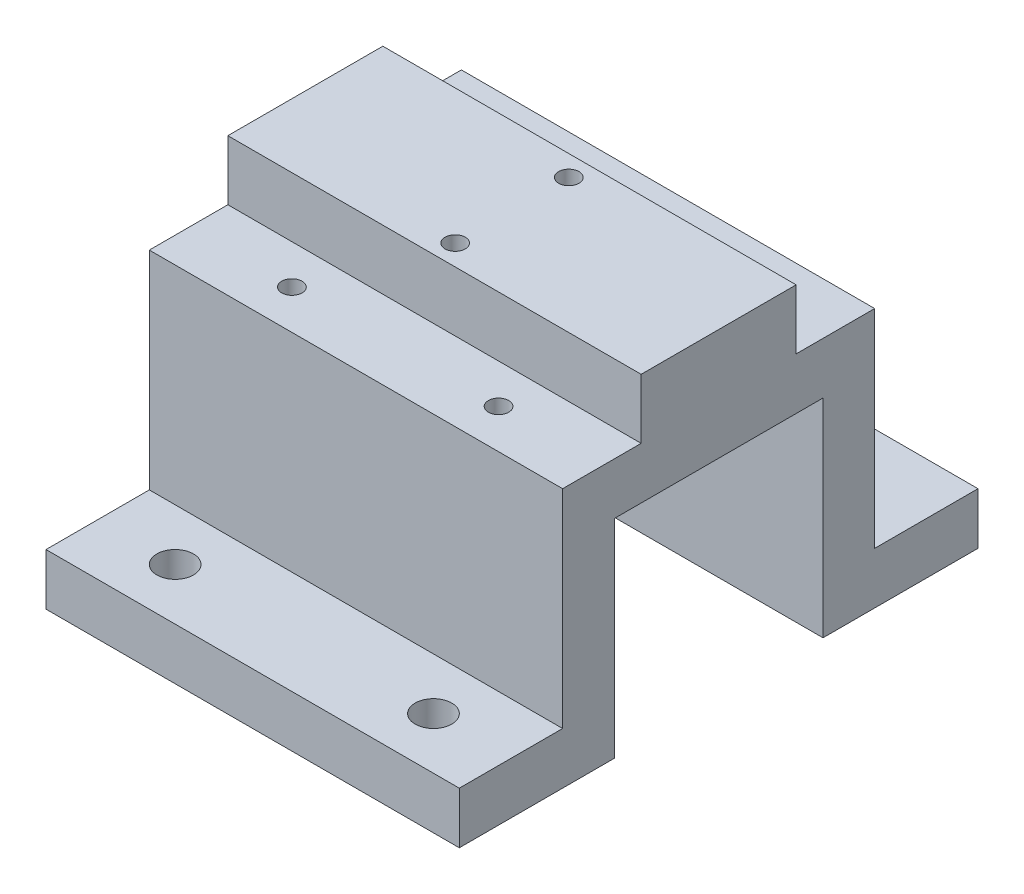
from build123d import *

# Parameters (mm, degrees)
SKETCH1_W                 = 12.7
SKETCH1_H                 = 6.35
BOSS_EXTRUDE1_DEPTH       = 50.8
SKETCH2_W                 = 50.8
SKETCH2_H                 = 19.05
BOSS_EXTRUDE2_DEPTH       = 7.35076
M3X0_5_TAPPED_HOLE1_D     = 2.5
M3X0_5_TAPPED_HOLE1_DEPTH = 6.35
M3X0_5_TAPPED_HOLE1_TIP   = 0.751075774
M3X0_5_TAPPED_HOLE2_D     = 2.5
M4_CLEARANCE_HOLE1_D      = 4.5


with BuildPart() as part:
    # Sketch1 → Boss-Extrude1 (new body)
    with BuildSketch(Plane(origin=(0, 0, 0), x_dir=(0, 0, -1), z_dir=(1, 0, 0))):
        Polygon((19.177, 6.35), (19.177, 31.877), (0, 31.877), (0, 25.527), (12.827, 25.527), (12.827, 0), (19.177, 0), align=None)
        with Locations((25.527, 3.175)):
            Rectangle(SKETCH1_W, SKETCH1_H)
        Polygon((0, 25.527), (0, 31.877), (-19.177, 31.877), (-19.177, 6.35), (-19.177, 0), (-12.827, 0), (-12.827, 25.527), align=None)
        with Locations((-25.527, 3.175)):
            Rectangle(SKETCH1_W, SKETCH1_H)
    extrude(amount=BOSS_EXTRUDE1_DEPTH)

    # Sketch2 → Boss-Extrude2 (add)
    with BuildSketch(Plane(origin=(0, 31.877, 0), x_dir=(1, 0, 0), z_dir=(0, 1, 0))):
        with Locations((25.4, 0)):
            Rectangle(SKETCH2_W, SKETCH2_H)
    extrude(amount=BOSS_EXTRUDE2_DEPTH)

    # M3x0.5 Tapped Hole1
    with Locations(Plane(origin=(0, 39.22776, 0), x_dir=(1, 0, 0), z_dir=(0, 1, 0))):
        with Locations((25.4, -6.985), (25.4, 6.985)):
            Hole(M3X0_5_TAPPED_HOLE1_D / 2, depth=M3X0_5_TAPPED_HOLE1_DEPTH)
            with Locations((0, 0, -(M3X0_5_TAPPED_HOLE1_DEPTH + M3X0_5_TAPPED_HOLE1_TIP / 2))):  # 118° drill point
                Cone(0, M3X0_5_TAPPED_HOLE1_D / 2, M3X0_5_TAPPED_HOLE1_TIP, mode=Mode.SUBTRACT)

    # M3x0.5 Tapped Hole2 (through all)
    with Locations(Plane(origin=(0, 31.877, 0), x_dir=(1, 0, 0), z_dir=(0, 1, 0))):
        with Locations((38.1, 14.351), (12.7, 14.351)):
            m3x0_5_tapped_hole2 = Hole(M3X0_5_TAPPED_HOLE2_D / 2)

    # Mirror1: M3x0.5 Tapped Hole2 across plane
    add(m3x0_5_tapped_hole2.mirror(Plane.XY), mode=Mode.SUBTRACT)

    # M4 Clearance Hole1 (through all)
    with Locations(Plane(origin=(0, 6.35, 0), x_dir=(1, 0, 0), z_dir=(0, 1, 0))):
        with Locations((41.275, 25.527), (9.525, 25.527)):
            m4_clearance_hole1 = Hole(M4_CLEARANCE_HOLE1_D / 2)

    # Mirror2: M4 Clearance Hole1 across plane
    add(m4_clearance_hole1.mirror(Plane.XY), mode=Mode.SUBTRACT)


solid = part.part
